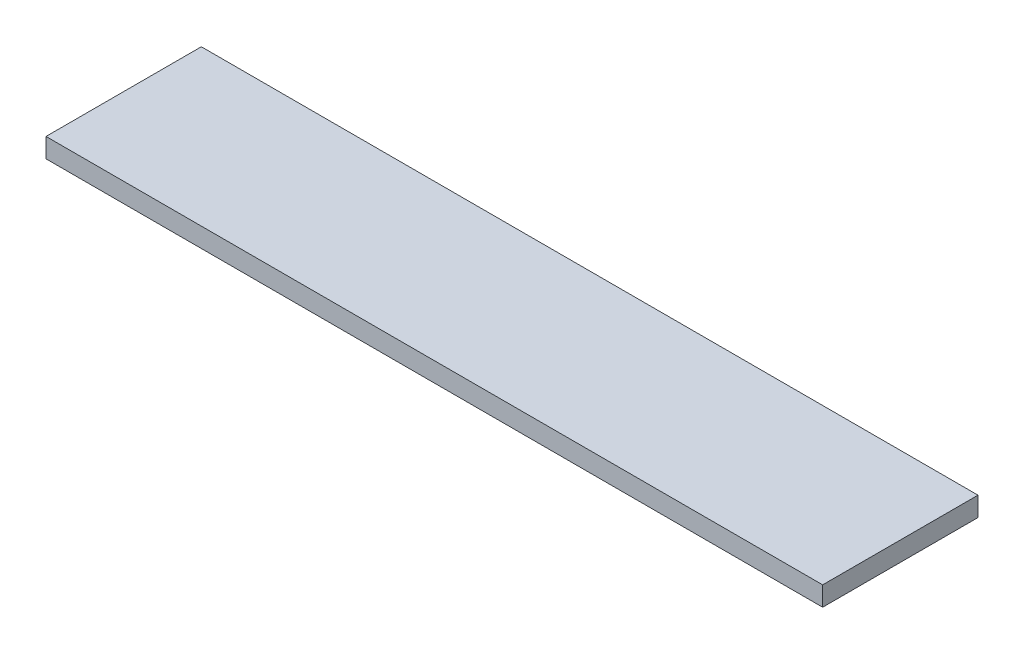
from build123d import *

# Parameters (mm, degrees)
SKETCH1_W           = 254
SKETCH1_H           = 50.8
BOSS_EXTRUDE1_DEPTH = 6.35


with BuildPart() as part:
    # Sketch1 → Boss-Extrude1 (new body)
    with BuildSketch(Plane(origin=(0, 0, 0), x_dir=(1, 0, 0), z_dir=(0, 1, 0))):
        with Locations((127, 25.4)):
            Rectangle(SKETCH1_W, SKETCH1_H)
    extrude(amount=BOSS_EXTRUDE1_DEPTH)


solid = part.part
